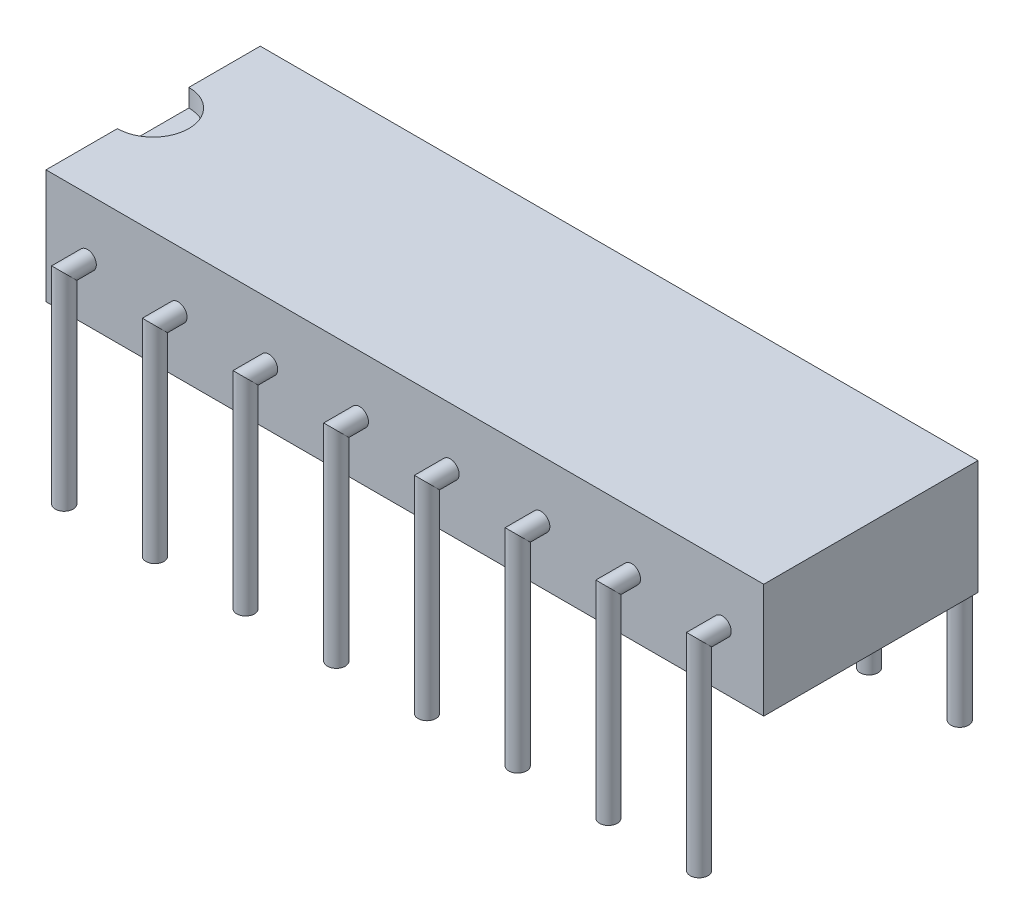
from build123d import *

# Parameters (mm, degrees)
ESQUISSE1_W                          = 6
ESQUISSE1_H                          = 3.2
EXTRUSION1_DEPTH                     = 20.1
ENL_V_MAT_EXTRU_1_DEPTH              = 0.5
ESQUISSE3_R                          = 0.25
R_P_TITION_LIN_AIRE1_COUNT           = 8
R_P_TITION_LIN_AIRE1_PITCH           = 2.54
R_P_TITION_LIN_AIRE1_COPY_1_SKETCH_R = 0.25
R_P_TITION_LIN_AIRE1_COPY_2_SKETCH_R = 0.25
R_P_TITION_LIN_AIRE1_COPY_3_SKETCH_R = 0.25
R_P_TITION_LIN_AIRE1_COPY_4_SKETCH_R = 0.25
R_P_TITION_LIN_AIRE1_COPY_5_SKETCH_R = 0.25
R_P_TITION_LIN_AIRE1_COPY_6_SKETCH_R = 0.25
R_P_TITION_LIN_AIRE1_COPY_7_SKETCH_R = 0.25


with BuildPart() as part:
    # Esquisse1 → Extrusion1 (new body)
    with BuildSketch(Plane(origin=(0, 0, 0), x_dir=(0, 0, -1), z_dir=(1, 0, 0))):
        with Locations((0, 1.6)):
            Rectangle(ESQUISSE1_W, ESQUISSE1_H)
    extrude(amount=EXTRUSION1_DEPTH)

    # Esquisse2 → Enlèv. mat.-Extru.1 (cut)
    with BuildSketch(Plane(origin=(0, 3.2, 0), x_dir=(-1, 0, 0), z_dir=(0, 1, 0))):
        with BuildLine():
            Line((0, -1), (0, 1))
            ThreePointArc((0, 1), (-1, 0), (0, -1))
        make_face()
    extrude(amount=-ENL_V_MAT_EXTRU_1_DEPTH, mode=Mode.SUBTRACT)

    # Balayage1: sweep along a path in Esquisse5
    with BuildLine(Plane(origin=(1.16, 0, 0), x_dir=(0, 0, -1), z_dir=(1, 0, 0))) as balayage1_path:
        Line((-3, 1.6), (-3.65, 1.6))
        Line((-3.65, 1.6), (-3.65, -4))
    # Esquisse3 → Balayage1 (sweep)
    with BuildSketch(Plane.XY.offset(3)):
        with Locations((1.16, 1.6)):
            Circle(ESQUISSE3_R)
    balayage1 = sweep(path=balayage1_path.line, transition=Transition.RIGHT)

    # Symétrie1: Balayage1 across plane
    add(balayage1.mirror(Plane.XY))

    # Répétition linéaire1: Balayage1 ×8
    with Locations(*[(i * R_P_TITION_LIN_AIRE1_PITCH, 0, 0) for i in range(1, R_P_TITION_LIN_AIRE1_COUNT)]):
        add(balayage1)

    # Répétition linéaire1 copy 1: sweep along a path in Répétition linéaire1 copy 1 path
    with BuildLine(Plane(origin=(3.7, 0, 0), x_dir=(0, 0, 1), z_dir=(1, 0, 0))) as r_p_tition_lin_aire1_copy_1_path:
        Line((-3, -1.6), (-3.65, -1.6))
        Line((-3.65, -1.6), (-3.65, 4))
    # Répétition linéaire1 copy 1 sketch → Répétition linéaire1 copy 1 (sweep)
    with BuildSketch(Plane(origin=(2.54, 0, -3), x_dir=(1, 0, 0), z_dir=(0, 0, -1))):
        with Locations((1.16, -1.6)):
            Circle(R_P_TITION_LIN_AIRE1_COPY_1_SKETCH_R)
    sweep(path=r_p_tition_lin_aire1_copy_1_path.line, transition=Transition.RIGHT)

    # Répétition linéaire1 copy 2: sweep along a path in Répétition linéaire1 copy 2 path
    with BuildLine(Plane(origin=(6.24, 0, 0), x_dir=(0, 0, 1), z_dir=(1, 0, 0))) as r_p_tition_lin_aire1_copy_2_path:
        Line((-3, -1.6), (-3.65, -1.6))
        Line((-3.65, -1.6), (-3.65, 4))
    # Répétition linéaire1 copy 2 sketch → Répétition linéaire1 copy 2 (sweep)
    with BuildSketch(Plane(origin=(5.08, 0, -3), x_dir=(1, 0, 0), z_dir=(0, 0, -1))):
        with Locations((1.16, -1.6)):
            Circle(R_P_TITION_LIN_AIRE1_COPY_2_SKETCH_R)
    sweep(path=r_p_tition_lin_aire1_copy_2_path.line, transition=Transition.RIGHT)

    # Répétition linéaire1 copy 3: sweep along a path in Répétition linéaire1 copy 3 path
    with BuildLine(Plane(origin=(8.78, 0, 0), x_dir=(0, 0, 1), z_dir=(1, 0, 0))) as r_p_tition_lin_aire1_copy_3_path:
        Line((-3, -1.6), (-3.65, -1.6))
        Line((-3.65, -1.6), (-3.65, 4))
    # Répétition linéaire1 copy 3 sketch → Répétition linéaire1 copy 3 (sweep)
    with BuildSketch(Plane(origin=(7.62, 0, -3), x_dir=(1, 0, 0), z_dir=(0, 0, -1))):
        with Locations((1.16, -1.6)):
            Circle(R_P_TITION_LIN_AIRE1_COPY_3_SKETCH_R)
    sweep(path=r_p_tition_lin_aire1_copy_3_path.line, transition=Transition.RIGHT)

    # Répétition linéaire1 copy 4: sweep along a path in Répétition linéaire1 copy 4 path
    with BuildLine(Plane(origin=(11.32, 0, 0), x_dir=(0, 0, 1), z_dir=(1, 0, 0))) as r_p_tition_lin_aire1_copy_4_path:
        Line((-3, -1.6), (-3.65, -1.6))
        Line((-3.65, -1.6), (-3.65, 4))
    # Répétition linéaire1 copy 4 sketch → Répétition linéaire1 copy 4 (sweep)
    with BuildSketch(Plane(origin=(10.16, 0, -3), x_dir=(1, 0, 0), z_dir=(0, 0, -1))):
        with Locations((1.16, -1.6)):
            Circle(R_P_TITION_LIN_AIRE1_COPY_4_SKETCH_R)
    sweep(path=r_p_tition_lin_aire1_copy_4_path.line, transition=Transition.RIGHT)

    # Répétition linéaire1 copy 5: sweep along a path in Répétition linéaire1 copy 5 path
    with BuildLine(Plane(origin=(13.86, 0, 0), x_dir=(0, 0, 1), z_dir=(1, 0, 0))) as r_p_tition_lin_aire1_copy_5_path:
        Line((-3, -1.6), (-3.65, -1.6))
        Line((-3.65, -1.6), (-3.65, 4))
    # Répétition linéaire1 copy 5 sketch → Répétition linéaire1 copy 5 (sweep)
    with BuildSketch(Plane(origin=(12.7, 0, -3), x_dir=(1, 0, 0), z_dir=(0, 0, -1))):
        with Locations((1.16, -1.6)):
            Circle(R_P_TITION_LIN_AIRE1_COPY_5_SKETCH_R)
    sweep(path=r_p_tition_lin_aire1_copy_5_path.line, transition=Transition.RIGHT)

    # Répétition linéaire1 copy 6: sweep along a path in Répétition linéaire1 copy 6 path
    with BuildLine(Plane(origin=(16.4, 0, 0), x_dir=(0, 0, 1), z_dir=(1, 0, 0))) as r_p_tition_lin_aire1_copy_6_path:
        Line((-3, -1.6), (-3.65, -1.6))
        Line((-3.65, -1.6), (-3.65, 4))
    # Répétition linéaire1 copy 6 sketch → Répétition linéaire1 copy 6 (sweep)
    with BuildSketch(Plane(origin=(15.24, 0, -3), x_dir=(1, 0, 0), z_dir=(0, 0, -1))):
        with Locations((1.16, -1.6)):
            Circle(R_P_TITION_LIN_AIRE1_COPY_6_SKETCH_R)
    sweep(path=r_p_tition_lin_aire1_copy_6_path.line, transition=Transition.RIGHT)

    # Répétition linéaire1 copy 7: sweep along a path in Répétition linéaire1 copy 7 path
    with BuildLine(Plane(origin=(18.94, 0, 0), x_dir=(0, 0, 1), z_dir=(1, 0, 0))) as r_p_tition_lin_aire1_copy_7_path:
        Line((-3, -1.6), (-3.65, -1.6))
        Line((-3.65, -1.6), (-3.65, 4))
    # Répétition linéaire1 copy 7 sketch → Répétition linéaire1 copy 7 (sweep)
    with BuildSketch(Plane(origin=(17.78, 0, -3), x_dir=(1, 0, 0), z_dir=(0, 0, -1))):
        with Locations((1.16, -1.6)):
            Circle(R_P_TITION_LIN_AIRE1_COPY_7_SKETCH_R)
    sweep(path=r_p_tition_lin_aire1_copy_7_path.line, transition=Transition.RIGHT)


solid = part.part
